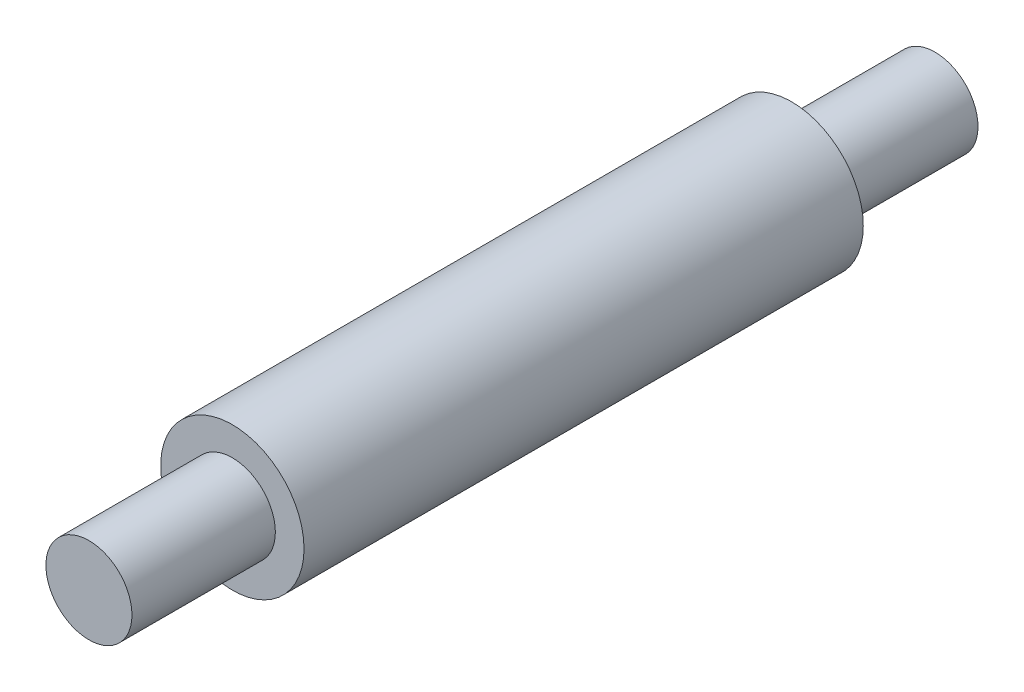
from build123d import *


with BuildPart() as part:
    # Sketch6 → Revolve1 (revolve)
    with BuildSketch(Plane(origin=(0, 0, 0), x_dir=(0, 0, -1), z_dir=(1, 0, 0))):
        Polygon((0, 0), (59, 0), (59, 3), (49, 3), (49, 5), (10, 5), (10, 3), (0, 3), align=None)
    revolve(axis=Axis((0, 0, 0), (0, 0, -1)))


solid = part.part
